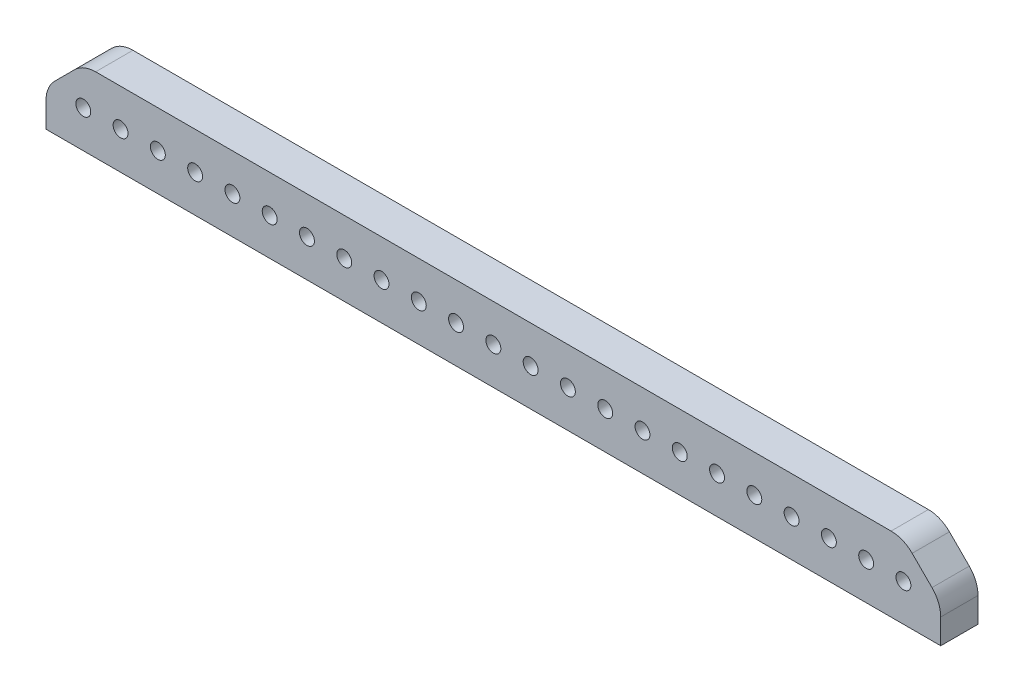
from build123d import *

# Parameters (mm, degrees)
SKETCH1_W           = 152.4
SKETCH1_H           = 12.7
BOSS_EXTRUDE1_DEPTH = 6.35
SKETCH2_R           = 1.27
CUT_EXTRUDE1_DEPTH  = 7.35
LPATTERN1_COUNT     = 12
LPATTERN1_PITCH     = 6.35
LPATTERN1_COL_COUNT = 12
LPATTERN1_COL_PITCH = 6.35
CHAMFER1_SIZE       = 6.35
FILLET1_R           = 5.08


with BuildPart() as part:
    # Sketch1 → Boss-Extrude1 (new body)
    with BuildSketch(Plane.XY):
        Rectangle(SKETCH1_W, SKETCH1_H)
    extrude(amount=BOSS_EXTRUDE1_DEPTH)

    # Sketch2 → Cut-Extrude1 (cut, through all)
    with BuildSketch(Plane.XY.offset(6.35)):
        Circle(SKETCH2_R)
    cut_extrude1 = extrude(amount=-CUT_EXTRUDE1_DEPTH, mode=Mode.SUBTRACT)

    # LPattern1: Cut-Extrude1 ×12
    with Locations(*[(i * LPATTERN1_PITCH, 0, 0) for i in range(1, LPATTERN1_COUNT)]):
        add(cut_extrude1, mode=Mode.SUBTRACT)

    # LPattern1 col: Cut-Extrude1 ×12
    with Locations(*[(-i * LPATTERN1_COL_PITCH, 0, 0) for i in range(1, LPATTERN1_COL_COUNT)]):
        add(cut_extrude1, mode=Mode.SUBTRACT)

    # Chamfer1
    chamfer1_edges = [part.edges().sort_by_distance(p)[0] for p in [
        (-76.2, 6.35, 3.175),
        (76.2, 6.35, 3.175),
    ]]
    chamfer(chamfer1_edges, length=CHAMFER1_SIZE)

    # Fillet1
    fillet1_edges = [part.edges().sort_by_distance(p)[0] for p in [
        (-69.85, 6.35, 3.175),
        (69.85, 6.35, 3.175),
        (76.2, 0, 3.175),
        (-76.2, 0, 3.175),
    ]]
    fillet(fillet1_edges, radius=FILLET1_R)


solid = part.part
